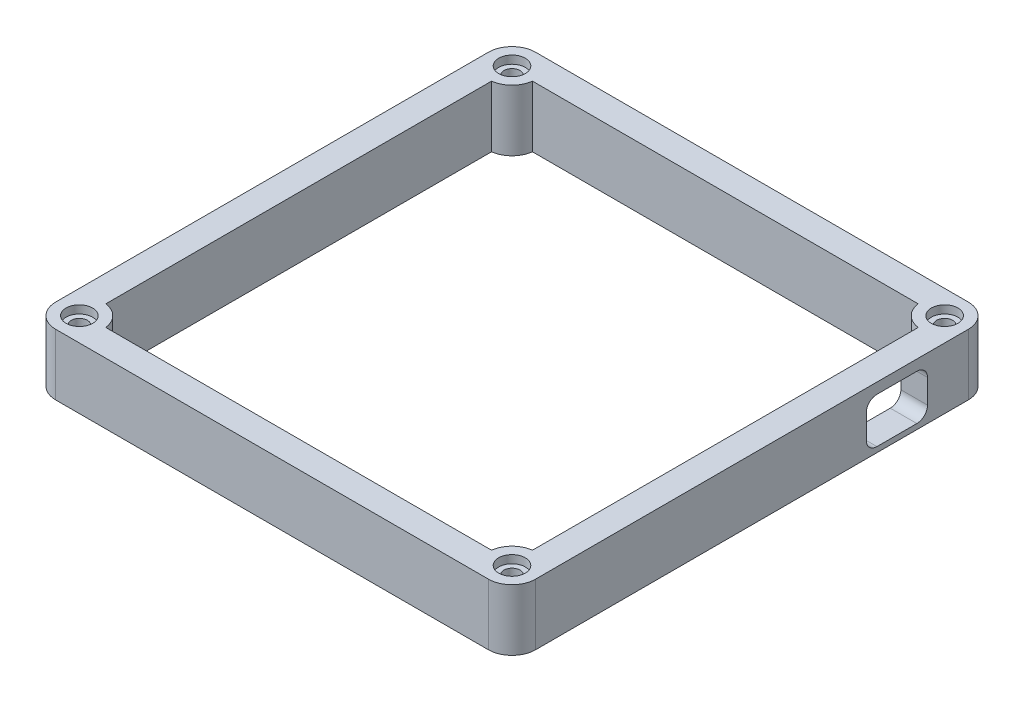
from build123d import *

# Parameters (mm, degrees)
SKETCH1_W           = 7.937979337
SKETCH1_H           = 0.559115352
BOSS_EXTRUDE1_DEPTH = 11.5
SKETCH2_R           = 1.5
CUT_EXTRUDE1_DEPTH  = 8
CUT_EXTRUDE2_DEPTH  = 8
SKETCH4_R           = 2.5
CUT_EXTRUDE3_DEPTH  = 1.5


with BuildPart() as part:
    # Sketch1 → Boss-Extrude1 (new body)
    with BuildSketch(Plane(origin=(0, 0, 0), x_dir=(1, 0, 0), z_dir=(0, 1, 0))):
        with BuildLine():
            Line((-40.080884648, -36.23445276), (-40.080884648, 18.423402639))
            Line((-40.080884648, 18.423402639), (-40.64, 18.423402639))
            Line((-40.64, 18.423402639), (-40.64, -36.199115352))
            ThreePointArc((-40.64, -36.199115352), (-40.359884529, -36.207958509), (-40.080884648, -36.23445276))
        make_face()
        with BuildLine():
            Line((-40.080884648, 18.423402639), (-40.080884648, 36.23445276))
            ThreePointArc((-40.080884648, 36.23445276), (-40.359884529, 36.207958509), (-40.64, 36.199115352))
            Line((-40.64, 36.199115352), (-40.64, 18.423402639))
            Line((-40.64, 18.423402639), (-40.080884648, 18.423402639))
        make_face()
        with BuildLine():
            Line((-36.23445276, 40.080884648), (-7.937979337, 40.080884648))
            Line((-7.937979337, 40.080884648), (-7.937979337, 40.64))
            Line((-7.937979337, 40.64), (-36.199115352, 40.64))
            ThreePointArc((-36.199115352, 40.64), (-36.207958509, 40.359884529), (-36.23445276, 40.080884648))
        make_face()
        with BuildLine():
            Line((0, 40.64), (0, 40.080884648))
            Line((0, 40.080884648), (36.23445276, 40.080884648))
            ThreePointArc((36.23445276, 40.080884648), (36.207958509, 40.359884529), (36.199115352, 40.64))
            Line((36.199115352, 40.64), (0, 40.64))
        make_face()
        with Locations((-3.968989669, 40.360442324)):
            Rectangle(SKETCH1_W, SKETCH1_H)
        with BuildLine():
            ThreePointArc((40.64, 36.199115352), (40.359884529, 36.207958509), (40.080884648, 36.23445276))
            Line((40.080884648, 36.23445276), (40.080884648, 28.268480093))
            Line((40.080884648, 28.268480093), (40.64, 28.268480093))
            Line((40.64, 28.268480093), (40.64, 36.199115352))
        make_face()
        with BuildLine():
            Line((40.64, 28.268480093), (40.080884648, 28.268480093))
            Line((40.080884648, 28.268480093), (40.080884648, -36.23445276))
            ThreePointArc((40.080884648, -36.23445276), (40.359884529, -36.207958509), (40.64, -36.199115352))
            Line((40.64, -36.199115352), (40.64, 28.268480093))
        make_face()
        with BuildLine():
            ThreePointArc((40.64, -36.199115352), (40.359884529, -36.207958509), (40.080884648, -36.23445276))
            ThreePointArc((40.080884648, -36.23445276), (37.499820351, -37.499820351), (36.23445276, -40.080884648))
            ThreePointArc((36.23445276, -40.080884648), (36.207958509, -40.359884529), (36.199115352, -40.64))
            Line((36.199115352, -40.64), (40.64, -40.64))
            Line((40.64, -40.64), (40.64, -36.199115352))
        make_face()
        with BuildLine():
            ThreePointArc((45.080884648, -40.64), (43.780179649, -37.499820351), (40.64, -36.199115352))
            Line((40.64, -36.199115352), (40.64, -40.64))
            Line((40.64, -40.64), (36.199115352, -40.64))
            ThreePointArc((36.199115352, -40.64), (37.499820351, -43.780179649), (40.64, -45.080884648))
            ThreePointArc((40.64, -45.080884648), (43.780179649, -43.780179649), (45.080884648, -40.64))
        make_face()
        with BuildLine():
            ThreePointArc((36.199115352, -40.64), (36.207958509, -40.359884529), (36.23445276, -40.080884648))
            Line((36.23445276, -40.080884648), (27.085817246, -40.080884648))
            Line((27.085817246, -40.080884648), (27.085817246, -40.64))
            Line((27.085817246, -40.64), (36.199115352, -40.64))
        make_face()
        with BuildLine():
            Line((27.085817246, -40.080884648), (-36.23445276, -40.080884648))
            ThreePointArc((-36.23445276, -40.080884648), (-36.207958509, -40.359884529), (-36.199115352, -40.64))
            Line((-36.199115352, -40.64), (27.085817246, -40.64))
            Line((27.085817246, -40.64), (27.085817246, -40.080884648))
        make_face()
        with BuildLine():
            Line((-40.64, -40.64), (-40.64, -36.199115352))
            ThreePointArc((-40.64, -36.199115352), (-43.780179649, -37.499820351), (-45.080884648, -40.64))
            ThreePointArc((-45.080884648, -40.64), (-43.780179649, -43.780179649), (-40.64, -45.080884648))
            ThreePointArc((-40.64, -45.080884648), (-37.499820351, -43.780179649), (-36.199115352, -40.64))
            Line((-36.199115352, -40.64), (-40.64, -40.64))
        make_face()
        with BuildLine():
            ThreePointArc((-36.23445276, -40.080884648), (-37.499820351, -37.499820351), (-40.080884648, -36.23445276))
            ThreePointArc((-40.080884648, -36.23445276), (-40.359884529, -36.207958509), (-40.64, -36.199115352))
            Line((-40.64, -36.199115352), (-40.64, -40.64))
            Line((-40.64, -40.64), (-36.199115352, -40.64))
            ThreePointArc((-36.199115352, -40.64), (-36.207958509, -40.359884529), (-36.23445276, -40.080884648))
        make_face()
        with BuildLine():
            Line((27.085817246, -40.64), (-36.199115352, -40.64))
            ThreePointArc((-36.199115352, -40.64), (-37.499820351, -43.780179649), (-40.64, -45.080884648))
            Line((-40.64, -45.080884648), (27.085817246, -45.080884648))
            Line((27.085817246, -45.080884648), (27.085817246, -40.64))
        make_face()
        with BuildLine():
            Line((-40.64, -36.199115352), (-40.64, 18.423402639))
            Line((-40.64, 18.423402639), (-45.080884648, 18.423402639))
            Line((-45.080884648, 18.423402639), (-45.080884648, -40.64))
            ThreePointArc((-45.080884648, -40.64), (-43.780179649, -37.499820351), (-40.64, -36.199115352))
        make_face()
        with BuildLine():
            ThreePointArc((40.64, -45.080884648), (37.499820351, -43.780179649), (36.199115352, -40.64))
            Line((36.199115352, -40.64), (27.085817246, -40.64))
            Line((27.085817246, -40.64), (27.085817246, -45.080884648))
            Line((27.085817246, -45.080884648), (40.64, -45.080884648))
        make_face()
        with BuildLine():
            Line((45.080884648, 28.268480093), (40.64, 28.268480093))
            Line((40.64, 28.268480093), (40.64, -36.199115352))
            ThreePointArc((40.64, -36.199115352), (43.780179649, -37.499820351), (45.080884648, -40.64))
            Line((45.080884648, -40.64), (45.080884648, 28.268480093))
        make_face()
        with BuildLine():
            ThreePointArc((45.080884648, 40.64), (43.780179649, 37.499820351), (40.64, 36.199115352))
            Line((40.64, 36.199115352), (40.64, 28.268480093))
            Line((40.64, 28.268480093), (45.080884648, 28.268480093))
            Line((45.080884648, 28.268480093), (45.080884648, 40.64))
        make_face()
        with BuildLine():
            ThreePointArc((40.64, 45.080884648), (37.499820351, 43.780179649), (36.199115352, 40.64))
            Line((36.199115352, 40.64), (40.64, 40.64))
            Line((40.64, 40.64), (40.64, 36.199115352))
            ThreePointArc((40.64, 36.199115352), (43.780179649, 37.499820351), (45.080884648, 40.64))
            ThreePointArc((45.080884648, 40.64), (43.780179649, 43.780179649), (40.64, 45.080884648))
        make_face()
        with BuildLine():
            ThreePointArc((36.199115352, 40.64), (36.207958509, 40.359884529), (36.23445276, 40.080884648))
            ThreePointArc((36.23445276, 40.080884648), (37.499820351, 37.499820351), (40.080884648, 36.23445276))
            ThreePointArc((40.080884648, 36.23445276), (40.359884529, 36.207958509), (40.64, 36.199115352))
            Line((40.64, 36.199115352), (40.64, 40.64))
            Line((40.64, 40.64), (36.199115352, 40.64))
        make_face()
        with BuildLine():
            Line((-7.937979337, 40.64), (0, 40.64))
            Line((0, 40.64), (36.199115352, 40.64))
            ThreePointArc((36.199115352, 40.64), (37.499820351, 43.780179649), (40.64, 45.080884648))
            Line((40.64, 45.080884648), (-7.937979337, 45.080884648))
            Line((-7.937979337, 45.080884648), (-7.937979337, 40.64))
        make_face()
        with BuildLine():
            Line((-36.199115352, 40.64), (-7.937979337, 40.64))
            Line((-7.937979337, 40.64), (-7.937979337, 45.080884648))
            Line((-7.937979337, 45.080884648), (-40.64, 45.080884648))
            ThreePointArc((-40.64, 45.080884648), (-37.499820351, 43.780179649), (-36.199115352, 40.64))
        make_face()
        with BuildLine():
            Line((-40.64, 40.64), (-36.199115352, 40.64))
            ThreePointArc((-36.199115352, 40.64), (-37.499820351, 43.780179649), (-40.64, 45.080884648))
            ThreePointArc((-40.64, 45.080884648), (-43.780179649, 43.780179649), (-45.080884648, 40.64))
            ThreePointArc((-45.080884648, 40.64), (-43.780179649, 37.499820351), (-40.64, 36.199115352))
            Line((-40.64, 36.199115352), (-40.64, 40.64))
        make_face()
        with BuildLine():
            ThreePointArc((-40.080884648, 36.23445276), (-37.499820351, 37.499820351), (-36.23445276, 40.080884648))
            ThreePointArc((-36.23445276, 40.080884648), (-36.207958509, 40.359884529), (-36.199115352, 40.64))
            Line((-36.199115352, 40.64), (-40.64, 40.64))
            Line((-40.64, 40.64), (-40.64, 36.199115352))
            ThreePointArc((-40.64, 36.199115352), (-40.359884529, 36.207958509), (-40.080884648, 36.23445276))
        make_face()
        with BuildLine():
            Line((-40.64, 18.423402639), (-40.64, 36.199115352))
            ThreePointArc((-40.64, 36.199115352), (-43.780179649, 37.499820351), (-45.080884648, 40.64))
            Line((-45.080884648, 40.64), (-45.080884648, 18.423402639))
            Line((-45.080884648, 18.423402639), (-40.64, 18.423402639))
        make_face()
    extrude(amount=BOSS_EXTRUDE1_DEPTH)

    # Sketch2 → Cut-Extrude1 (cut)
    with BuildSketch(Plane(origin=(0, 11.5, 0), x_dir=(1, 0, 0), z_dir=(0, 1, 0))):
        with Locations((-40.64, 40.64)):
            Circle(SKETCH2_R)
        with Locations((40.64, 40.64)):
            Circle(SKETCH2_R)
        with Locations((40.64, -40.64)):
            Circle(SKETCH2_R)
        with Locations((-40.64, -40.64)):
            Circle(SKETCH2_R)
    extrude(amount=-CUT_EXTRUDE1_DEPTH, mode=Mode.SUBTRACT)

    # Sketch3 → Cut-Extrude2 (cut)
    with BuildSketch(Plane(origin=(45.080884648, 0, 0), x_dir=(0, 0, -1), z_dir=(1, 0, 0))):
        with BuildLine():
            Line((30.979, 9.5), (23.479, 9.5))
            ThreePointArc((23.479, 9.5), (22.064786438, 8.914213562), (21.479, 7.5))
            Line((21.479, 7.5), (21.479, 3))
            ThreePointArc((21.479, 3), (22.064786438, 1.585786438), (23.479, 1))
            Line((23.479, 1), (30.979, 1))
            ThreePointArc((30.979, 1), (32.393213562, 1.585786438), (32.979, 3))
            Line((32.979, 3), (32.979, 7.5))
            ThreePointArc((32.979, 7.5), (32.393213562, 8.914213562), (30.979, 9.5))
        make_face()
    extrude(amount=-CUT_EXTRUDE2_DEPTH, mode=Mode.SUBTRACT)

    # Sketch4 → Cut-Extrude3 (cut)
    with BuildSketch(Plane(origin=(0, 11.5, 0), x_dir=(1, 0, 0), z_dir=(0, 1, 0))):
        with Locations((-40.64, 40.64)):
            Circle(SKETCH4_R)
        with Locations((40.64, 40.64)):
            Circle(SKETCH4_R)
        with Locations((40.64, -40.64)):
            Circle(SKETCH4_R)
        with Locations((-40.64, -40.64)):
            Circle(SKETCH4_R)
    extrude(amount=-CUT_EXTRUDE3_DEPTH, mode=Mode.SUBTRACT)


solid = part.part
